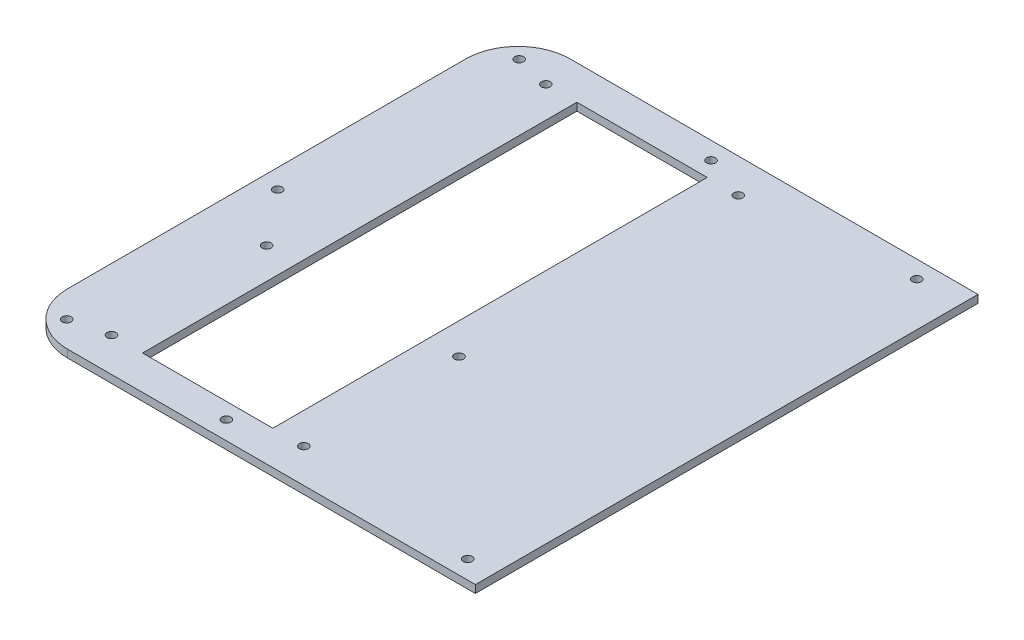
from build123d import *

# Parameters (mm, degrees)
BOSS_EXTRUDE1_DEPTH         = 3.175
SKETCH3_W                   = 53.34
SKETCH3_H                   = 177.8
CUT_EXTRUDE1_DEPTH          = 3.175
F_27_0_144_DIAMETER_HOLE2_D = 3.6576
F_27_0_144_DIAMETER_HOLE3_D = 3.6576
SKETCH12_W                  = 127
SKETCH12_H                  = 254
CUT_EXTRUDE2_DEPTH          = 25.4


with BuildPart() as part:
    # Sketch2 → Boss-Extrude1 (new body)
    with BuildSketch(Plane(origin=(0, 0, 0), x_dir=(1, 0, 0), z_dir=(0, 1, 0))):
        with BuildLine():
            Line((-106.934, -102.87), (106.934, -102.87))
            ThreePointArc((106.934, -102.87), (122.020830283, -96.620830283), (128.27, -81.534))
            Line((128.27, -81.534), (128.27, 81.534))
            ThreePointArc((128.27, 81.534), (122.020830283, 96.620830283), (106.934, 102.87))
            Line((106.934, 102.87), (-106.934, 102.87))
            ThreePointArc((-106.934, 102.87), (-122.020830283, 96.620830283), (-128.27, 81.534))
            Line((-128.27, 81.534), (-128.27, -81.534))
            ThreePointArc((-128.27, -81.534), (-122.020830283, -96.620830283), (-106.934, -102.87))
        make_face()
    extrude(amount=BOSS_EXTRUDE1_DEPTH)

    # Sketch3 → Cut-Extrude1 (cut)
    with BuildSketch(Plane(origin=(0, 0, 0), x_dir=(1, 0, 0), z_dir=(0, 1, 0))):
        with Locations((-63.5, 0)):
            Rectangle(SKETCH3_W, SKETCH3_H)
    extrude(amount=CUT_EXTRUDE1_DEPTH, mode=Mode.SUBTRACT)

    # #27 (0.144) Diameter Hole2 (through all)
    with Locations(Plane(origin=(0, 3.175, 0), x_dir=(1, 0, 0), z_dir=(0, 1, 0))):
        with Locations((-24.13, -25.4), (-24.13, 88.9), (-102.87, 88.9), (-102.87, -25.4), (-102.87, -88.9), (-24.13, -88.9)):
            Hole(F_27_0_144_DIAMETER_HOLE2_D / 2)

    # #27 (0.144) Diameter Hole3 (through all)
    with Locations(Plane(origin=(0, 3.175, 0), x_dir=(1, 0, 0), z_dir=(0, 1, 0))):
        with Locations((-42.1132, 95.7453), (42.1132, 95.7453), (117.221, 92.2909), (117.6274, -92.5195), (49.403, -95.3643), (120.4468, -3.3147), (-49.403, -95.3643), (-117.6274, -92.5195), (-120.4468, -3.3147), (-117.221, 92.2909)):
            Hole(F_27_0_144_DIAMETER_HOLE3_D / 2)

    # Sketch12 → Cut-Extrude2 (cut)
    with BuildSketch(Plane(origin=(0, 3.175, 0), x_dir=(1, 0, 0), z_dir=(0, 1, 0))):
        with Locations((123.5456, 0)):
            Rectangle(SKETCH12_W, SKETCH12_H)
    extrude(amount=-CUT_EXTRUDE2_DEPTH, mode=Mode.SUBTRACT)


solid = part.part
